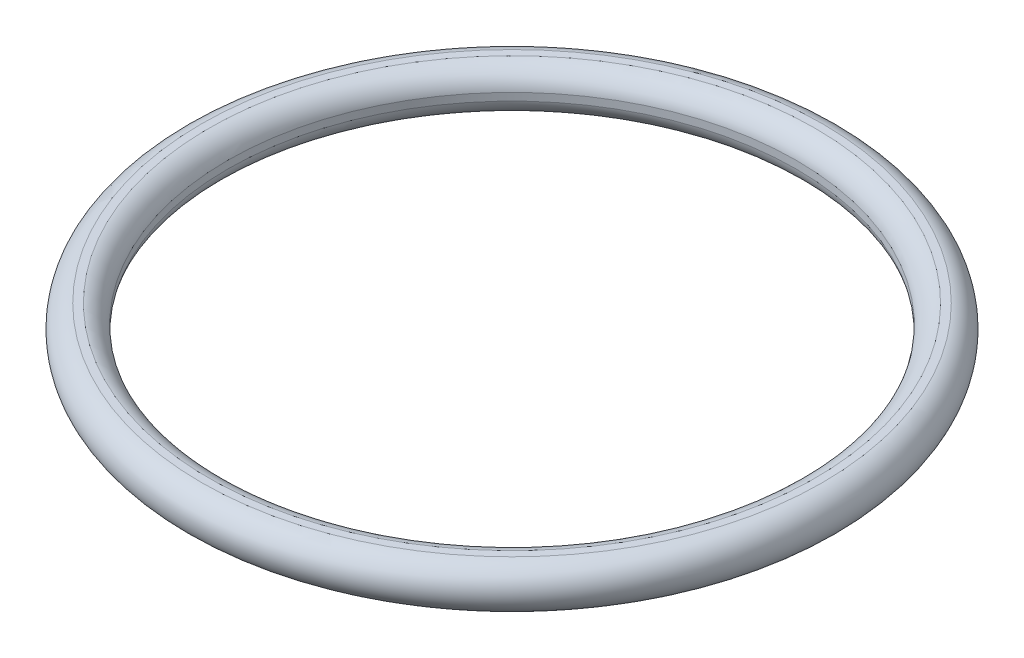
from build123d import *


with BuildPart() as part:
    # Эскиз1 → Повернуть1 (revolve)
    with BuildSketch(Plane.XY):
        with BuildLine():
            Line((9.410490027, 0.125), (9.410490027, -0.125))
            ThreePointArc((9.410490027, -0.125), (10.680330086, -0.530330086), (10.275, 0.739509973))
            Line((10.275, 0.739509973), (10.025, 0.739509973))
            ThreePointArc((10.025, 0.739509973), (9.619669914, 0.530330086), (9.410490027, 0.125))
        make_face()
    revolve(axis=Axis((0, 0, 0), (0, 1, 0)))


solid = part.part
